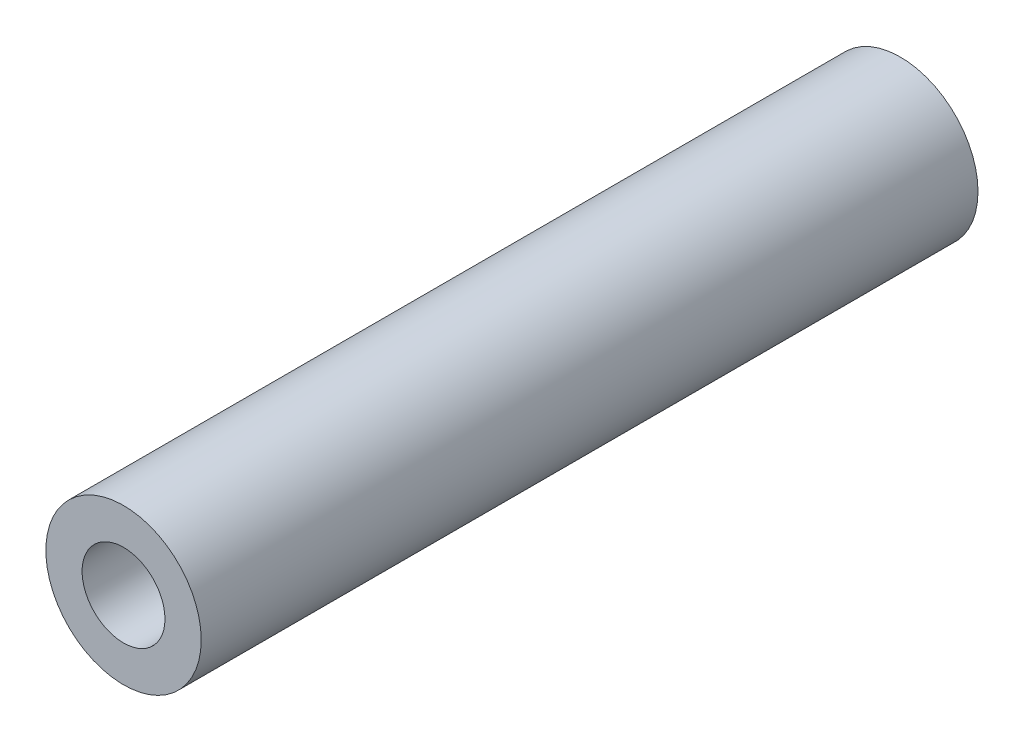
from build123d import *

# Parameters (mm, degrees)
SKETCH1_R           = 3
SKETCH1_R_2         = 1.6
EXTRUDE1_DEPTH      = 15
EXTRUDE1_DEPTH_BACK = 15


with BuildPart() as part:
    # Sketch1 → Extrude1 (new body, two sides)
    with BuildSketch(Plane.XY) as extrude1_sk:
        Circle(SKETCH1_R)
        Circle(SKETCH1_R_2, mode=Mode.SUBTRACT)
    extrude(amount=EXTRUDE1_DEPTH)
    extrude(extrude1_sk.sketch, amount=-EXTRUDE1_DEPTH_BACK)


solid = part.part
